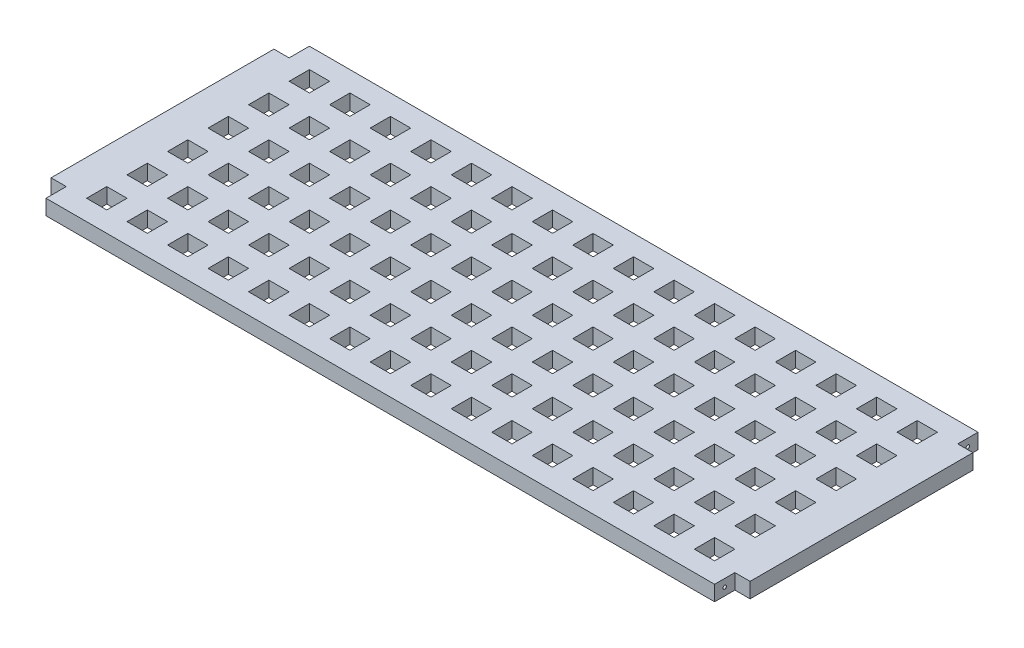
from build123d import *

# Parameters (mm, degrees)
BOSS_EXTRUDE2_DEPTH                      = 15
SKETCH2_W                                = 20
SKETCH2_H                                = 20
CUT_EXTRUDE1_DEPTH                       = 15
LPATTERN1_COUNT                          = 16
LPATTERN1_PITCH                          = 40
LPATTERN1_COUNT_DIR2                     = 6
LPATTERN1_PITCH_DIR2                     = 40
M3_CLEARANCE_HOLE2_D                     = 3.4
M3_CLEARANCE_HOLE2_DEPTH                 = 13.978536948
M3_CLEARANCE_HOLE2_CSINK_D               = 3.45
M3_CLEARANCE_HOLE2_CSINK_ANGLE           = 90
M3_CLEARANCE_HOLE2_TIP                   = 1.021463052
M3_CLEARANCE_HOLE3_D                     = 3.4
M3_CLEARANCE_HOLE3_DEPTH                 = 13.978536948
M3_CLEARANCE_HOLE3_CSINK_D               = 3.45
M3_CLEARANCE_HOLE3_CSINK_ANGLE           = 90
M3_CLEARANCE_HOLE3_TIP                   = 1.021463052
M3_CLEARANCE_HOLE3_ON_FACE_2_D           = 3.4
M3_CLEARANCE_HOLE3_ON_FACE_2_DEPTH       = 13.978536948
M3_CLEARANCE_HOLE3_ON_FACE_2_CSINK_D     = 3.45
M3_CLEARANCE_HOLE3_ON_FACE_2_CSINK_ANGLE = 90
M3_CLEARANCE_HOLE3_ON_FACE_2_TIP         = 1.021463052


with BuildPart() as part:
    # Sketch1 → Boss-Extrude2 (new body)
    with BuildSketch(Plane(origin=(0, 0, 0), x_dir=(1, 0, 0), z_dir=(0, 1, 0))):
        Polygon((-373.376737441, 133.843710292), (-358.376737441, 133.843710292), (-358.376737441, 153.843710292), (301.623262559, 153.843710292), (301.623262559, 133.843710292), (316.623262559, 133.843710292), (316.623262559, -86.156289708), (301.623262559, -86.156289708), (301.623262559, -106.156289708), (-358.376737441, -106.156289708), (-358.376737441, -86.156289708), (-373.376737441, -86.156289708), align=None)
    extrude(amount=-BOSS_EXTRUDE2_DEPTH)

    # Sketch2 → Cut-Extrude1 (cut)
    with BuildSketch(Plane(origin=(0, 0, 0), x_dir=(1, 0, 0), z_dir=(0, 1, 0))):
        with Locations((-328.376737441, 123.843710292)):
            Rectangle(SKETCH2_W, SKETCH2_H)
    cut_extrude1 = extrude(amount=-CUT_EXTRUDE1_DEPTH, mode=Mode.SUBTRACT)

    # LPattern1: Cut-Extrude1 16 × 6
    with Locations(*[(i * LPATTERN1_PITCH, 0, j * LPATTERN1_PITCH_DIR2) for i in range(LPATTERN1_COUNT) for j in range(LPATTERN1_COUNT_DIR2) if (i, j) != (0, 0)]):
        add(cut_extrude1, mode=Mode.SUBTRACT)

    # M3 Clearance Hole2
    with Locations(Plane(origin=(301.623262559, -7.5, -143.843710292), x_dir=(0, 0, 1), z_dir=(1, 0, 0))):
        with Locations((0, 0), (240, 0)):
            CounterSinkHole(M3_CLEARANCE_HOLE2_D / 2, M3_CLEARANCE_HOLE2_CSINK_D / 2, depth=M3_CLEARANCE_HOLE2_DEPTH, counter_sink_angle=M3_CLEARANCE_HOLE2_CSINK_ANGLE)
            with Locations((0, 0, -(M3_CLEARANCE_HOLE2_DEPTH + M3_CLEARANCE_HOLE2_TIP / 2))):  # 118° drill point
                Cone(0, M3_CLEARANCE_HOLE2_D / 2, M3_CLEARANCE_HOLE2_TIP, mode=Mode.SUBTRACT)

    # M3 Clearance Hole3
    with Locations(Plane(origin=(-358.376737441, -7.5, -143.843710292), x_dir=(0, 0, -1), z_dir=(-1, 0, 0))):
        with Locations((0, 0), (-240, 0)):
            CounterSinkHole(M3_CLEARANCE_HOLE3_D / 2, M3_CLEARANCE_HOLE3_CSINK_D / 2, depth=M3_CLEARANCE_HOLE3_DEPTH, counter_sink_angle=M3_CLEARANCE_HOLE3_CSINK_ANGLE)
            with Locations((0, 0, -(M3_CLEARANCE_HOLE3_DEPTH + M3_CLEARANCE_HOLE3_TIP / 2))):  # 118° drill point
                Cone(0, M3_CLEARANCE_HOLE3_D / 2, M3_CLEARANCE_HOLE3_TIP, mode=Mode.SUBTRACT)

    # M3 Clearance Hole3 on face 2
    with Locations(Plane(origin=(-225.572474151, 7.657152829, 0), x_dir=(0, 0, -1), z_dir=(-1, 0, 0))):
        with Locations((0, 0)):
            CounterSinkHole(M3_CLEARANCE_HOLE3_ON_FACE_2_D / 2, M3_CLEARANCE_HOLE3_ON_FACE_2_CSINK_D / 2, depth=M3_CLEARANCE_HOLE3_ON_FACE_2_DEPTH, counter_sink_angle=M3_CLEARANCE_HOLE3_ON_FACE_2_CSINK_ANGLE)
            with Locations((0, 0, -(M3_CLEARANCE_HOLE3_ON_FACE_2_DEPTH + M3_CLEARANCE_HOLE3_ON_FACE_2_TIP / 2))):  # 118° drill point
                Cone(0, M3_CLEARANCE_HOLE3_ON_FACE_2_D / 2, M3_CLEARANCE_HOLE3_ON_FACE_2_TIP, mode=Mode.SUBTRACT)


solid = part.part
